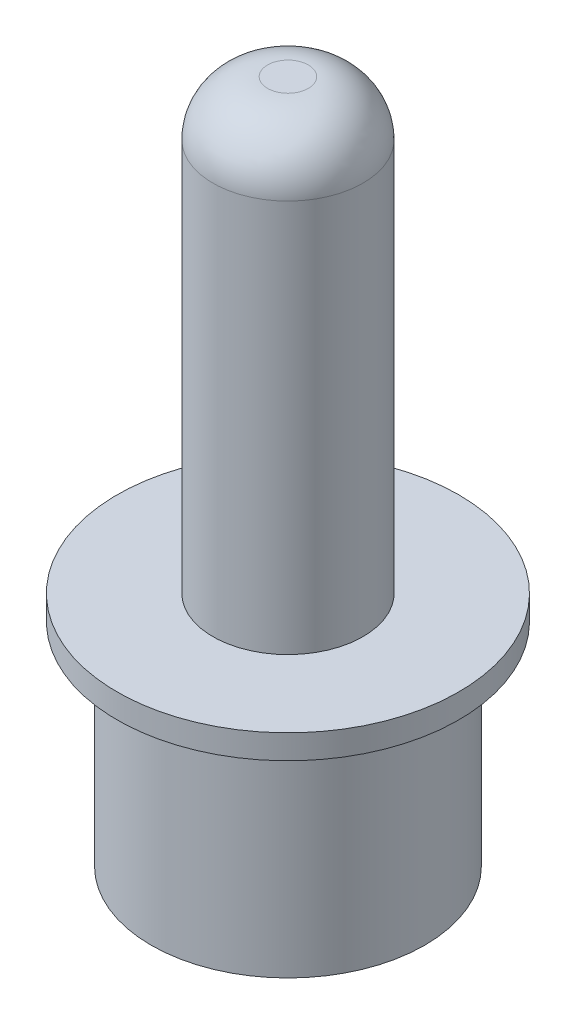
from build123d import *

# Parameters (mm, degrees)
FILLET1_R          = 2
SKETCH2_R          = 1.5
CUT_EXTRUDE1_DEPTH = 18


with BuildPart() as part:
    # Sketch1 → Revolve1 (revolve)
    with BuildSketch(Plane.XY):
        Polygon((0, 0), (0, 25), (-2.744112853, 25), (-2.744112853, 8.642091449), (-6.244112853, 8.642091449), (-6.244112853, 7.755870593), (-5, 7.343117412), (-5, 0), align=None)
    revolve(axis=Axis((0, 0, 0), (0, 1, 0)))

    # Fillet1
    fillet1_edges = [part.edges().sort_by_distance(p)[0] for p in [
        (2.744112853, 25, 0),
    ]]
    fillet(fillet1_edges, radius=FILLET1_R)

    # Sketch2 → Cut-Extrude1 (cut)
    with BuildSketch(Plane.XZ):
        Circle(SKETCH2_R)
    extrude(amount=-CUT_EXTRUDE1_DEPTH, mode=Mode.SUBTRACT)


solid = part.part
